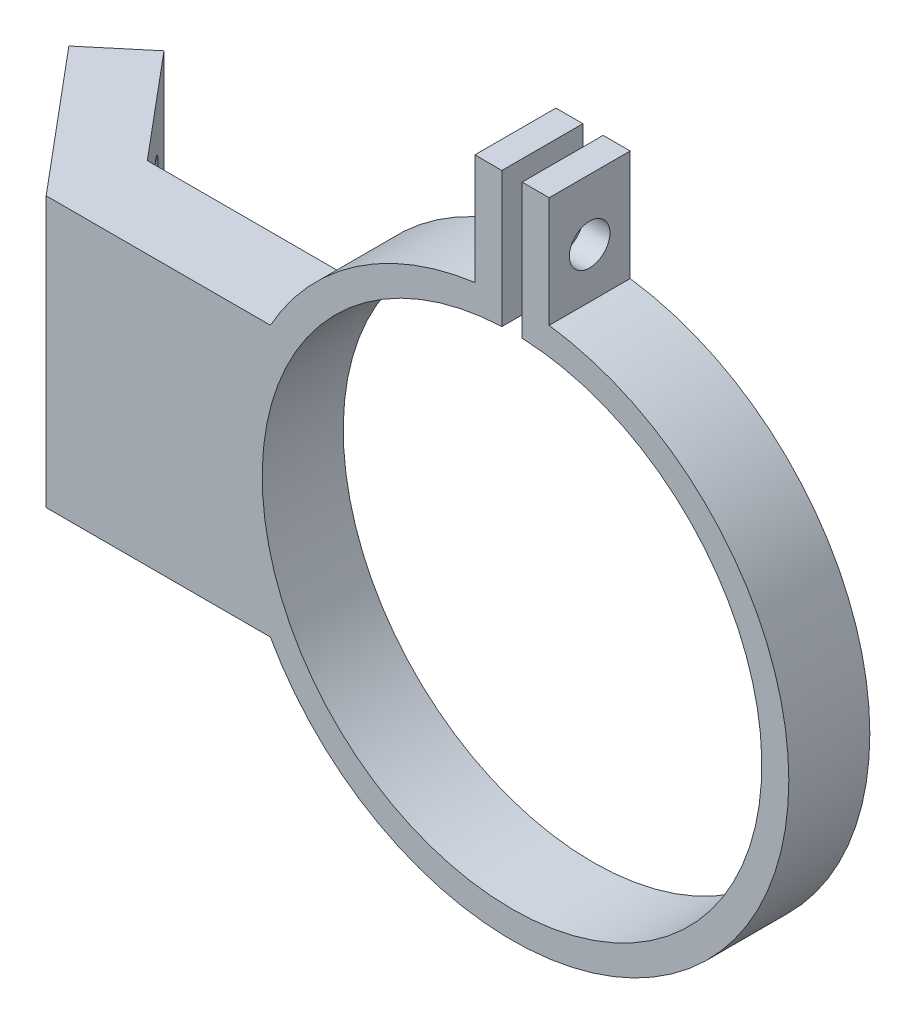
from build123d import *

# Parameters (mm, degrees)
BOSS_EXTRUDE1_DEPTH             = 3
SKETCH2_R                       = 1.5
CUT_EXTRUDE1_DEPTH              = 21.5
CUT_EXTRUDE1_DEPTH_BACK         = 35.5
BOSS_EXTRUDE2_REACH             = 30.5
BOSS_EXTRUDE2_DIRECTION_2_REACH = 22.5
SKETCH4_R                       = 1.5
CUT_EXTRUDE2_DEPTH              = 46.913208795
CUT_EXTRUDE2_DEPTH_BACK         = 12.714884867


with BuildPart() as part:
    # Sketch1 → Boss-Extrude1 (new body, symmetric)
    with BuildSketch(Plane.XY):
        with BuildLine():
            ThreePointArc((20.5, 0), (15.437373481, 13.48842096), (2.75, 20.314711418))
            Line((2.75, 20.314711418), (2.75, 18.294466376))
            ThreePointArc((2.75, 18.294466376), (14.020074893, 12.070107705), (18.5, 0))
            ThreePointArc((18.5, 0), (-12.070107705, -14.020074893), (-2.75, 18.294466376))
            Line((-2.75, 18.294466376), (-2.75, 20.314711418))
            ThreePointArc((-2.75, 20.314711418), (-11.53940193, 16.943795416), (-17.895530168, 10))
            ThreePointArc((-17.895530168, 10), (-20.5, 0), (-17.895530168, -10))
            ThreePointArc((-17.895530168, -10), (5.166799374, -19.838200126), (20.5, 0))
        make_face()
        with BuildLine():
            ThreePointArc((2.75, 20.314711418), (1.752101194, 20.424988162), (0.75, 20.486275894))
            Line((0.75, 20.486275894), (0.75, 18.484791046))
            ThreePointArc((0.75, 18.484791046), (1.752585481, 18.416797879), (2.75, 18.294466376))
            Line((2.75, 18.294466376), (2.75, 20.314711418))
        make_face()
        with BuildLine():
            Line((-0.75, 18.484791046), (-0.75, 20.486275894))
            ThreePointArc((-0.75, 20.486275894), (-1.752101194, 20.424988162), (-2.75, 20.314711418))
            Line((-2.75, 20.314711418), (-2.75, 18.294466376))
            ThreePointArc((-2.75, 18.294466376), (-1.752585481, 18.416797879), (-0.75, 18.484791046))
        make_face()
        with BuildLine():
            ThreePointArc((-2.75, 20.314711418), (-1.752101194, 20.424988162), (-0.75, 20.486275894))
            Line((-0.75, 20.486275894), (-0.75, 28.5))
            Line((-0.75, 28.5), (-2.75, 28.5))
            Line((-2.75, 28.5), (-2.75, 25.5))
            Line((-2.75, 25.5), (-2.75, 22.5))
            Line((-2.75, 22.5), (-2.75, 20.314711418))
        make_face()
        with BuildLine():
            Line((2.75, 25.5), (2.75, 28.5))
            Line((2.75, 28.5), (0.75, 28.5))
            Line((0.75, 28.5), (0.75, 20.486275894))
            ThreePointArc((0.75, 20.486275894), (1.752101194, 20.424988162), (2.75, 20.314711418))
            Line((2.75, 20.314711418), (2.75, 22.5))
            Line((2.75, 22.5), (2.75, 25.5))
        make_face()
        with BuildLine():
            Line((-20.5, -10), (-17.895530168, -10))
            ThreePointArc((-17.895530168, -10), (-20.5, 0), (-17.895530168, 10))
            Line((-17.895530168, 10), (-20.5, 10))
            Line((-20.5, 10), (-34.5, 10))
            Line((-34.5, 10), (-34.5, -10))
            Line((-34.5, -10), (-20.5, -10))
        make_face()
    extrude(amount=BOSS_EXTRUDE1_DEPTH, both=True)

    # Sketch2 → Cut-Extrude1 (cut, two sides)
    with BuildSketch(Plane(origin=(0, 0, 0), x_dir=(0, 0, -1), z_dir=(1, 0, 0))) as cut_extrude1_sk:
        with Locations((0, 24)):
            Circle(SKETCH2_R)
    extrude(amount=CUT_EXTRUDE1_DEPTH, mode=Mode.SUBTRACT)
    extrude(cut_extrude1_sk.sketch, amount=-CUT_EXTRUDE1_DEPTH_BACK, mode=Mode.SUBTRACT)

    # Boss-Extrude2: up to this face of the body (flat: up to its plane)
    boss_extrude2_end = Plane(part.part.faces().sort_by_distance((-26.197765084, 10, 0))[0])
    # Sketch3 → Boss-Extrude2 (add, up to the picked face)
    with BuildSketch(Plane(origin=(0, 0, 0), x_dir=(1, 0, 0), z_dir=(0, 1, 0)), mode=Mode.PRIVATE) as boss_extrude2_sk1:
        Polygon((-34.5, -3), (-43.265659653, 7.446506383), (-39.435437437, 10.660444431), (-33.00756134, 3), align=None)
    boss_extrude2_tool1 = split(extrude(boss_extrude2_sk1.sketch, amount=BOSS_EXTRUDE2_REACH, mode=Mode.PRIVATE), bisect_by=boss_extrude2_end, keep=Keep.BOTH, mode=Mode.PRIVATE)
    add(boss_extrude2_tool1.solids().sort_by_distance((-37.620413, 0, -4.408594))[0])

    # Boss-Extrude2 direction 2: up to this face of the body (flat: up to its plane)
    boss_extrude2_direction_2_end = Plane(part.part.faces().sort_by_distance((-26.197765084, -10, 0))[0])
    # Sketch3 → Boss-Extrude2 direction 2 (add, up to the picked face)
    with BuildSketch(Plane(origin=(0, 0, 0), x_dir=(1, 0, 0), z_dir=(0, 1, 0)), mode=Mode.PRIVATE) as boss_extrude2_direction_2_sk1:
        Polygon((-34.5, -3), (-43.265659653, 7.446506383), (-39.435437437, 10.660444431), (-33.00756134, 3), align=None)
    boss_extrude2_direction_2_tool1 = split(extrude(boss_extrude2_direction_2_sk1.sketch, amount=-BOSS_EXTRUDE2_DIRECTION_2_REACH, mode=Mode.PRIVATE), bisect_by=boss_extrude2_direction_2_end, keep=Keep.BOTH, mode=Mode.PRIVATE)
    add(boss_extrude2_direction_2_tool1.solids().sort_by_distance((-37.620413, 0, -4.408594))[0])

    # Sketch4 → Cut-Extrude2 (cut, two sides)
    with BuildSketch(Plane(origin=(-17.892420479, 0, 15.013523425), x_dir=(-0.64278761, 0, -0.766044443), z_dir=(0.766044443, 0, -0.64278761))) as cut_extrude2_sk:
        with Locations((28.514984785, 5)):
            Circle(SKETCH4_R)
        with Locations((28.514984785, -5)):
            Circle(SKETCH4_R)
    extrude(amount=CUT_EXTRUDE2_DEPTH, mode=Mode.SUBTRACT)
    extrude(cut_extrude2_sk.sketch, amount=-CUT_EXTRUDE2_DEPTH_BACK, mode=Mode.SUBTRACT)


solid = part.part
